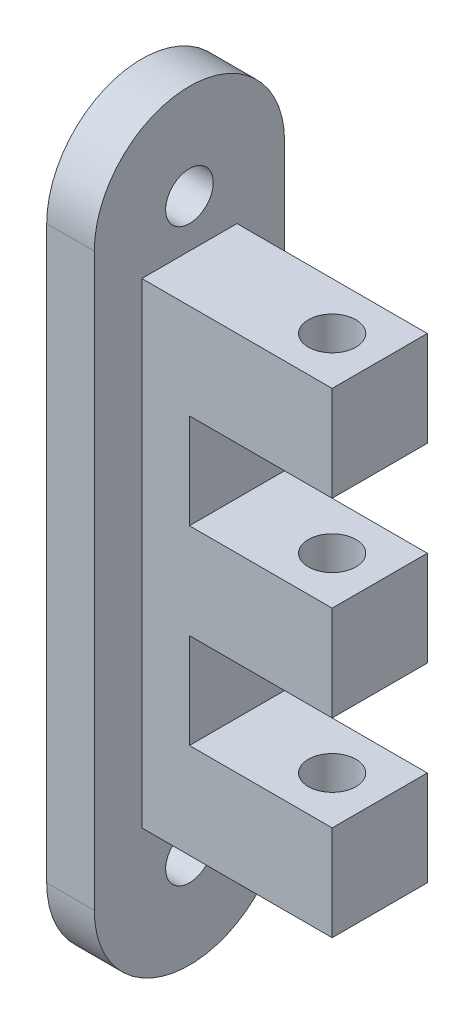
from build123d import *

# Parameters (mm, degrees)
SKETCH1_W      = 10
SKETCH1_H      = 160
EXTRUDE1_DEPTH = 20
FILLET1_RADIUS = 20
FILLET1_LENGTH = 10
FILLET2_RADIUS = 20
FILLET2_LENGTH = 10
SKETCH2_R      = 5
EXTRUDE2_DEPTH = 84.066238629
EXTRUDE3_DEPTH = 10
SKETCH4_R      = 5
EXTRUDE4_DEPTH = 138.477270849


with BuildPart() as part:
    # Sketch1 → Extrude1 (new, symmetric)
    with BuildSketch(Plane(origin=(0, 0, 0), x_dir=(-1, 0, 0), z_dir=(0, 0, -1))):
        with Locations((5, 0)):
            Rectangle(SKETCH1_W, SKETCH1_H)
    extrude(amount=EXTRUDE1_DEPTH, both=True)

    # Fillet1: full round fillet: the end face becomes a half cylinder, R = half its width
    fillet1_face = Plane((-5, 80, 0), x_dir=(-1, 0, 0), z_dir=(0, 1, 0))  # on the end face: x along it, z out of the body
    fillet1_slab = fillet1_face.offset(-FILLET1_RADIUS / 2) * Box(FILLET1_LENGTH, 2 * FILLET1_RADIUS, FILLET1_RADIUS, mode=Mode.PRIVATE)  # the body's end, R deep
    fillet1_round = Plane((-5, 60, 0), x_dir=(0, 1, 0), z_dir=(-1, 0, 0)) * Cylinder(FILLET1_RADIUS, FILLET1_LENGTH, mode=Mode.PRIVATE)  # its axis R under the face
    add(fillet1_slab - fillet1_round, mode=Mode.SUBTRACT)

    # Fillet2: full round fillet: the end face becomes a half cylinder, R = half its width
    fillet2_face = Plane((-5, -80, 0), x_dir=(-1, 0, 0), z_dir=(0, -1, 0))  # on the end face: x along it, z out of the body
    fillet2_slab = fillet2_face.offset(-FILLET2_RADIUS / 2) * Box(FILLET2_LENGTH, 2 * FILLET2_RADIUS, FILLET2_RADIUS, mode=Mode.PRIVATE)  # the body's end, R deep
    fillet2_round = Plane((-5, -60, 0), x_dir=(0, -1, 0), z_dir=(-1, 0, 0)) * Cylinder(FILLET2_RADIUS, FILLET2_LENGTH, mode=Mode.PRIVATE)  # its axis R under the face
    add(fillet2_slab - fillet2_round, mode=Mode.SUBTRACT)

    # Sketch2 → Extrude2 (cut, through all)
    with BuildSketch(Plane(origin=(0, 0, 0), x_dir=(0, 0, -1), z_dir=(1, 0, 0))):
        with Locations(Location((0, 60, 0), (0, 0, 90))):
            Circle(SKETCH2_R)
        with Locations(Location((0, -60, 0), (0, 0, 90))):
            Circle(SKETCH2_R)
    extrude(amount=-EXTRUDE2_DEPTH, mode=Mode.SUBTRACT)

    # Sketch3 → Extrude3 (add, symmetric)
    with BuildSketch(Plane.XY):
        Polygon((0, 50), (40, 50), (40, 30), (10, 30), (10, 10), (40, 10), (40, -10), (10, -10), (10, -30), (40, -30), (40, -50), (0, -50), align=None)
    extrude(amount=EXTRUDE3_DEPTH, both=True)

    # Sketch4 → Extrude4 (cut, through all)
    with BuildSketch(Plane(origin=(0, 50, 0), x_dir=(1, 0, 0), z_dir=(0, 1, 0))):
        with Locations(Location((30, 0, 0), (0, 0, 270))):
            Circle(SKETCH4_R)
    extrude(amount=-EXTRUDE4_DEPTH, mode=Mode.SUBTRACT)


solid = part.part
